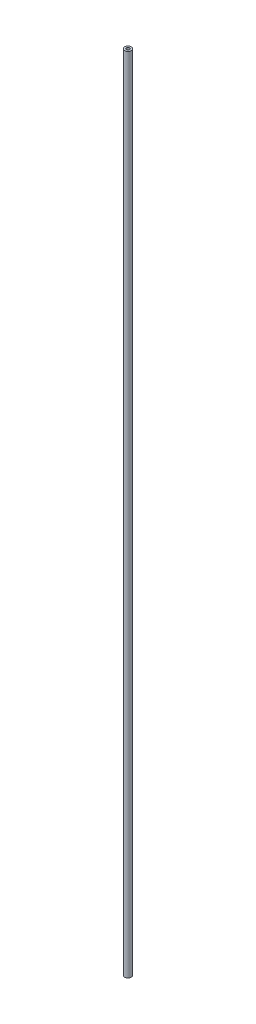
from build123d import *

# Parameters (mm, degrees)
BOSS_EXTRUDE1_DEPTH      = 120
BOSS_EXTRUDE1_DEPTH_BACK = 120
SKETCH1_R                = 1
SKETCH1_R_2              = 0.5


with BuildPart() as part:
    # Sketch1 → Boss-Extrude1 (new, two sides: drawn at the far end of the back side and taken through both)
    with BuildSketch(Plane(origin=(0, 0, 0), x_dir=(1, 0, 0), z_dir=(0, 1, 0)).offset(-BOSS_EXTRUDE1_DEPTH_BACK)):
        Circle(SKETCH1_R)
        Circle(SKETCH1_R_2, mode=Mode.SUBTRACT)
    extrude(amount=BOSS_EXTRUDE1_DEPTH + BOSS_EXTRUDE1_DEPTH_BACK)


solid = part.part
